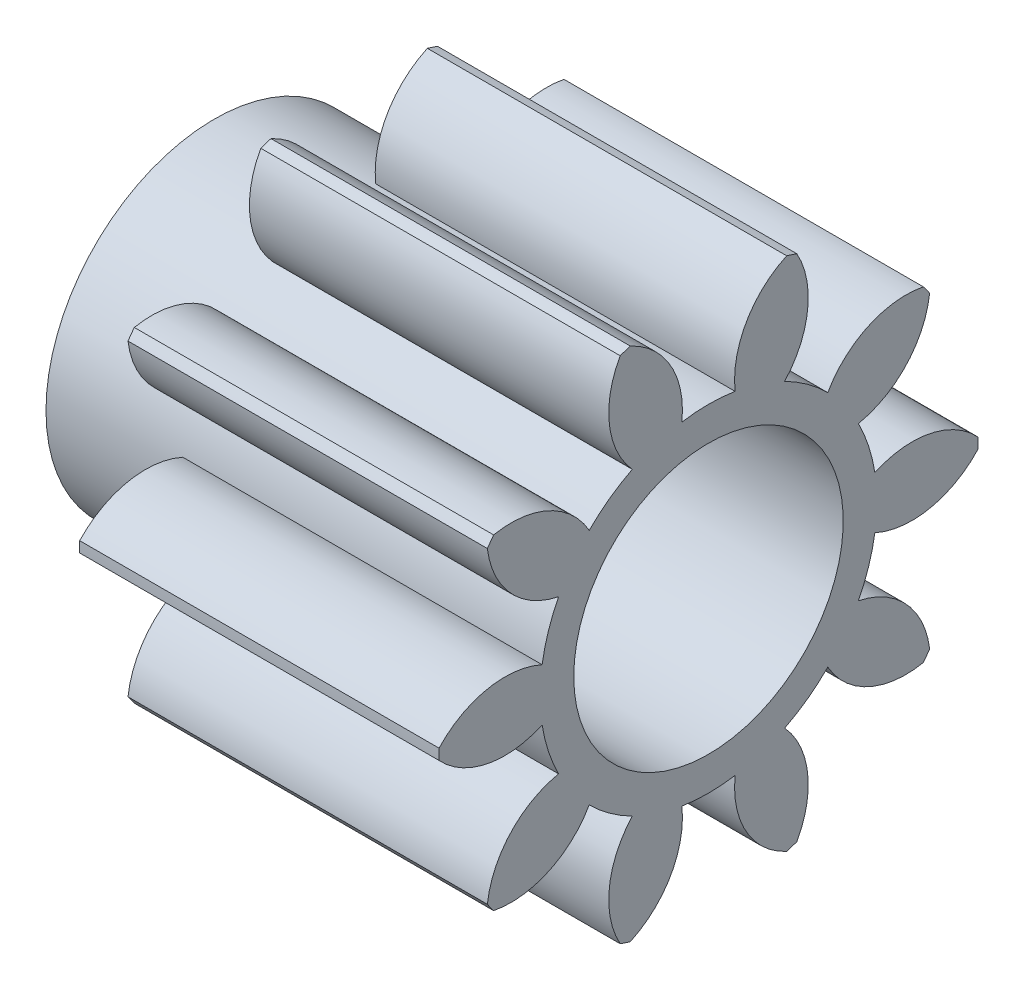
from build123d import *
from build123d.topology import SkipClean

# Parameters (mm, degrees)
BASPROSKE_W      = 8
BASPROSKE_H      = 6
TOOTHCUT_DEPTH   = 12.66190379
TEETHCUTS_COUNT  = 10
TEETHCUTS_ANGLE  = 324
HUBNEAONESKE_R   = 3.749
HUBNEARONE_DEPTH = 3.0000508
BORSKE_R         = 3
BORE_DEPTH       = 11.0000508


with BuildPart() as part:
    # BasProSke → Base-Revolve (revolve)
    with BuildSketch(Plane(origin=(0, 0, 0), x_dir=(1, 0, 0), z_dir=(0, 1, 0)), mode=Mode.PRIVATE) as base_revolve_sk:
        with Locations((4, 3)):
            Rectangle(BASPROSKE_W, BASPROSKE_H)
    revolve(base_revolve_sk.sketch.rotate(Axis((-10, 0, 0), (1, 0, 0)), 180), axis=Axis((-10, 0, 0), (1, 0, 0)))

    # TooCutSke → ToothCut (cut, through all)
    with BuildSketch(Plane(origin=(0, 0, 0), x_dir=(0, 0, -1), z_dir=(1, 0, 0))):
        with BuildLine():
            ThreePointArc((0.59278292, 3.701838653), (0, 3.749), (-0.59278292, 3.701838653))
            ThreePointArc((-0.59278292, 3.701838653), (-0.846593509, 4.924114224), (-1.775771316, 5.757784417))
            ThreePointArc((-1.775771316, 5.757784417), (0, 6.0254), (1.775771316, 5.757784417))
            ThreePointArc((1.775771316, 5.757784417), (0.846593509, 4.924114224), (0.59278292, 3.701838653))
        make_face()
    toothcut = extrude(amount=TOOTHCUT_DEPTH, mode=Mode.SUBTRACT)

    # TeethCuts: ToothCut ×10 about axis
    teethcuts_axis = Axis((0, 0, 0), (1, 0, 0))
    for i in range(1, TEETHCUTS_COUNT):
        add(toothcut.rotate(teethcuts_axis, i * TEETHCUTS_ANGLE / (TEETHCUTS_COUNT - 1)), mode=Mode.SUBTRACT)

    # HubNeaOneSke → HubNearOne (add)
    with SkipClean():  # the faces are left unmerged after this step: merging them gives an invalid solid
        with BuildSketch(Plane.ZY):
            Circle(HUBNEAONESKE_R)
        extrude(amount=HUBNEARONE_DEPTH)

    # BorSke → Bore (cut, symmetric)
    with SkipClean():  # the faces are left unmerged after this step: merging them gives an invalid solid
        with BuildSketch(Plane(origin=(0, 0, 0), x_dir=(0, 0, -1), z_dir=(1, 0, 0))):
            with Locations(Location((0, 0, 0), (0, 0, 180))):
                Circle(BORSKE_R)
        extrude(amount=BORE_DEPTH, both=True, mode=Mode.SUBTRACT)


solid = part.part
